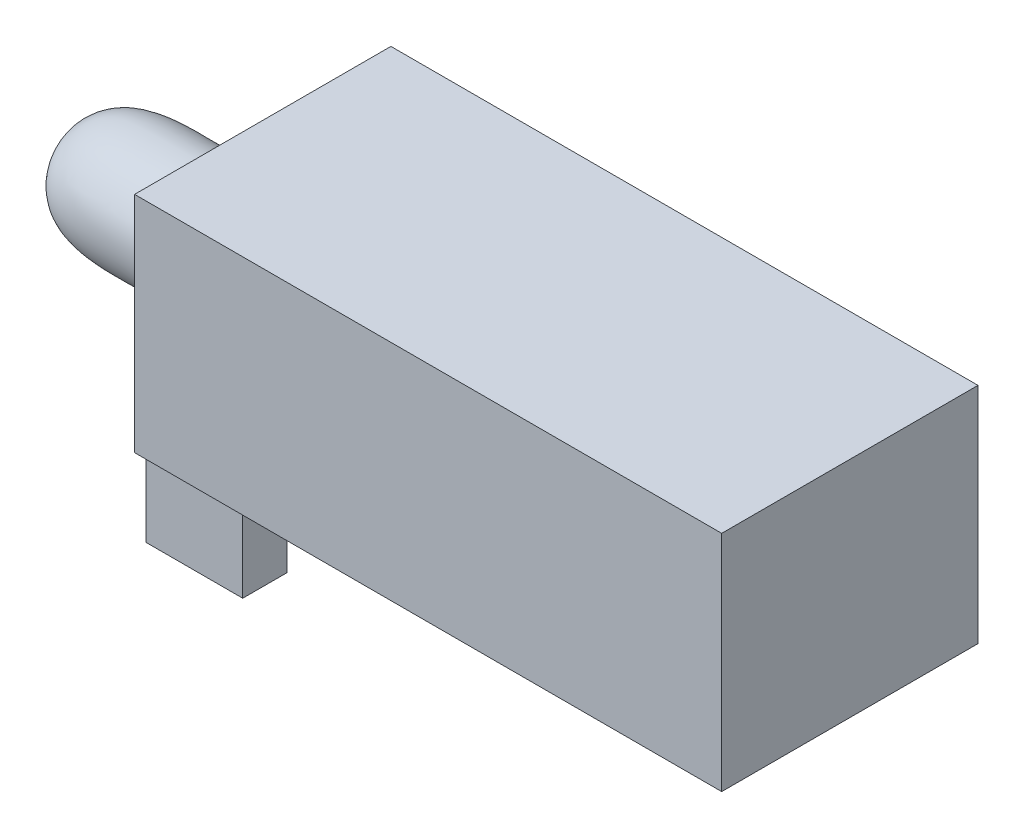
from build123d import *

# Parameters (mm, degrees)
SKETCH1_W           = 12.8
SKETCH1_H           = 5.588
BOSS_EXTRUDE1_DEPTH = 4.8768
SKETCH2_W           = 2.1082
SKETCH2_H           = 0.96
BOSS_EXTRUDE2_DEPTH = 1.82
SKETCH3_W           = 2.1082
SKETCH3_H           = 5.088
BOSS_EXTRUDE3_DEPTH = 0.2
BOSS_EXTRUDE4_DEPTH = 0.118


with BuildPart() as part:
    # Sketch1 → Boss-Extrude1 (new body)
    with BuildSketch(Plane(origin=(0, 0, 0), x_dir=(1, 0, 0), z_dir=(0, 1, 0))):
        Rectangle(SKETCH1_W, SKETCH1_H)
    extrude(amount=BOSS_EXTRUDE1_DEPTH)

    # Sketch2 → Boss-Extrude2 (add)
    with BuildSketch(Plane.XZ):
        with Locations((-5.3459, 2.064)):
            Rectangle(SKETCH2_W, SKETCH2_H)
        with Locations((-5.3459, -2.064)):
            Rectangle(SKETCH2_W, SKETCH2_H)
    extrude(amount=BOSS_EXTRUDE2_DEPTH)

    # Sketch3 → Boss-Extrude3 (add)
    with BuildSketch(Plane.XZ):
        with Locations((-5.3459, 0)):
            Rectangle(SKETCH3_W, SKETCH3_H)
    extrude(amount=BOSS_EXTRUDE3_DEPTH)


with BuildPart() as body_2:
    # Sketch4 → Boss-Extrude4 (new body)
    with BuildSketch(Plane.ZY.offset(6.5)):
        with BuildLine():
            Line((1.414219818, 3.548815479), (1.414219818, 0.720400865))
            ThreePointArc((1.414219818, 0.720400865), (-2, 2.134608172), (1.414219818, 3.548815479))
        make_face()
    extrude(amount=BOSS_EXTRUDE4_DEPTH)

    # Sketch5 → Revolve1 (revolve)
    with BuildSketch(Plane.XY):
        with BuildLine():
            Line((-6.618, 3.548815479), (-6.618, 2.134608172))
            Line((-6.618, 2.134608172), (-10.618, 2.134608172))
            add(Edge.make_bspline(
                [(-10.618, 2.134608172), (-10.478265298, 3.639589378), (-8.501963306, 3.288678842), (-7.033473389, 3.469874423), (-6.618, 3.548815479)],
                knots=[0, 0, 0, 0, 0.727688779, 1, 1, 1, 1], degree=3))
        make_face()
    revolve(axis=Axis((-6.618, 2.134608172, 0), (-1, 0, 0)))


solid = Compound([part.part, body_2.part])
